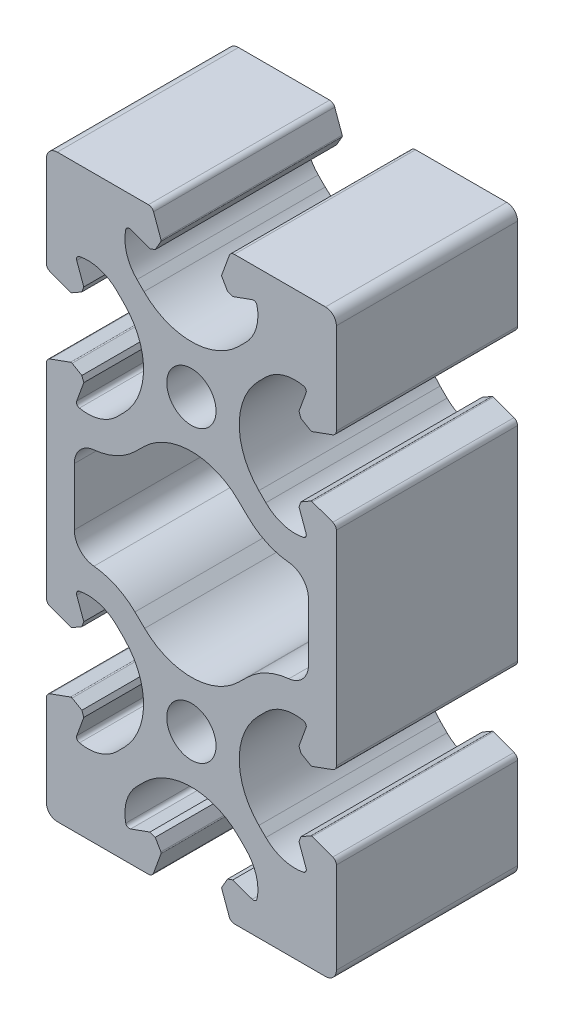
from build123d import *

# Parameters (mm, degrees)
SK_MAIN_EXTRUSION_R  = 3.4
MAIN_EXTRUSION_DEPTH = 25


with BuildPart() as part:
    # Sk Main Extrusion → Main Extrusion (new body)
    with BuildSketch(Plane.XY):
        with BuildLine():
            Line((16.671180212, 24.190076845), (19.506515108, 25.222054351))
            ThreePointArc((19.506515108, 25.222054351), (19.864364033, 25.496641489), (20, 25.926823816))
            Line((20, 25.926823816), (20, 38.5))
            ThreePointArc((20, 38.5), (19.560660172, 39.560660172), (18.5, 40))
            Line((18.5, 40), (5.926823816, 40))
            ThreePointArc((5.926823816, 40), (5.496641489, 39.864364033), (5.222054351, 39.506515107))
            Line((5.222054351, 39.506515107), (4.190076845, 36.671180212))
            ThreePointArc((4.190076845, 36.671180212), (4.175951326, 36.563886241), (4.208493649, 36.460675177))
            Line((4.208493649, 36.460675177), (4.987558066, 35.111296024))
            Line((4.987558066, 35.111296024), (5.718509166, 34.845251581))
            Line((5.718509166, 34.845251581), (8.396186179, 35.81984631))
            ThreePointArc((8.396186179, 35.81984631), (8.811074612, 35.786489799), (9.056960151, 35.450654467))
            ThreePointArc((9.056960151, 35.450654467), (8.933433013, 32.665882372), (7.504160339, 30.272684887))
            Line((7.504160339, 30.272684887), (6.540737726, 29.309262274))
            ThreePointArc((6.540737726, 29.309262274), (0, 26.6), (-6.540737726, 29.309262274))
            Line((-6.540737726, 29.309262274), (-7.504160339, 30.272684887))
            ThreePointArc((-7.504160339, 30.272684887), (-8.933433013, 32.665882372), (-9.056960151, 35.450654467))
            ThreePointArc((-9.056960151, 35.450654467), (-8.811074612, 35.786489799), (-8.396186179, 35.81984631))
            Line((-8.396186179, 35.81984631), (-5.718509166, 34.845251581))
            Line((-5.718509166, 34.845251581), (-4.987558066, 35.111296024))
            Line((-4.987558066, 35.111296024), (-4.208493649, 36.460675177))
            ThreePointArc((-4.208493649, 36.460675177), (-4.175951325, 36.563886241), (-4.190076845, 36.671180212))
            Line((-4.190076845, 36.671180212), (-5.222054351, 39.506515107))
            ThreePointArc((-5.222054351, 39.506515107), (-5.496641489, 39.864364033), (-5.926823816, 40))
            Line((-5.926823816, 40), (-18.5, 40))
            ThreePointArc((-18.5, 40), (-19.560660172, 39.560660172), (-20, 38.5))
            Line((-20, 38.5), (-20, 25.926823816))
            ThreePointArc((-20, 25.926823816), (-19.864364033, 25.496641489), (-19.506515107, 25.222054351))
            Line((-19.506515107, 25.222054351), (-16.671180212, 24.190076845))
            ThreePointArc((-16.671180212, 24.190076845), (-16.563886241, 24.175951326), (-16.460675176, 24.208493649))
            Line((-16.460675176, 24.208493649), (-15.111296024, 24.987558066))
            Line((-15.111296024, 24.987558066), (-14.845251581, 25.718509166))
            Line((-14.845251581, 25.718509166), (-15.81984631, 28.396186179))
            ThreePointArc((-15.81984631, 28.396186179), (-15.786489799, 28.811074612), (-15.450654467, 29.056960151))
            ThreePointArc((-15.450654467, 29.056960151), (-12.665882372, 28.933433013), (-10.272684887, 27.504160339))
            Line((-10.272684887, 27.504160339), (-9.309262274, 26.540737726))
            ThreePointArc((-9.309262274, 26.540737726), (-6.6, 20), (-9.309262274, 13.459262274))
            Line((-9.309262274, 13.459262274), (-10.272684887, 12.495839661))
            ThreePointArc((-10.272684887, 12.495839661), (-12.665882372, 11.066566987), (-15.450654467, 10.943039849))
            ThreePointArc((-15.450654467, 10.943039849), (-15.786489799, 11.188925388), (-15.81984631, 11.603813821))
            Line((-15.81984631, 11.603813821), (-14.845251581, 14.281490834))
            Line((-14.845251581, 14.281490834), (-15.111296024, 15.012441934))
            Line((-15.111296024, 15.012441934), (-16.460675176, 15.791506351))
            ThreePointArc((-16.460675176, 15.791506351), (-16.563886241, 15.824048675), (-16.671180212, 15.809923155))
            Line((-16.671180212, 15.809923155), (-19.506515107, 14.777945649))
            ThreePointArc((-19.506515107, 14.777945649), (-19.864364033, 14.503358511), (-20, 14.073176184))
            Line((-20, 14.073176184), (-20, -14.073176184))
            ThreePointArc((-20, -14.073176184), (-19.864364033, -14.503358511), (-19.506515107, -14.777945649))
            Line((-19.506515107, -14.777945649), (-16.671180212, -15.809923155))
            ThreePointArc((-16.671180212, -15.809923155), (-16.563886241, -15.824048675), (-16.460675176, -15.791506351))
            Line((-16.460675176, -15.791506351), (-15.111296024, -15.012441934))
            Line((-15.111296024, -15.012441934), (-14.845251581, -14.281490834))
            Line((-14.845251581, -14.281490834), (-15.81984631, -11.603813821))
            ThreePointArc((-15.81984631, -11.603813821), (-15.786489799, -11.188925388), (-15.450654467, -10.943039849))
            ThreePointArc((-15.450654467, -10.943039849), (-12.665882372, -11.066566987), (-10.272684887, -12.495839661))
            Line((-10.272684887, -12.495839661), (-9.309262274, -13.459262274))
            ThreePointArc((-9.309262274, -13.459262274), (-6.6, -20), (-9.309262274, -26.540737726))
            Line((-9.309262274, -26.540737726), (-10.272684887, -27.504160339))
            ThreePointArc((-10.272684887, -27.504160339), (-12.665882372, -28.933433013), (-15.450654467, -29.056960151))
            ThreePointArc((-15.450654467, -29.056960151), (-15.786489799, -28.811074612), (-15.81984631, -28.396186179))
            Line((-15.81984631, -28.396186179), (-14.845251581, -25.718509166))
            Line((-14.845251581, -25.718509166), (-15.111296024, -24.987558066))
            Line((-15.111296024, -24.987558066), (-16.460675176, -24.208493649))
            ThreePointArc((-16.460675176, -24.208493649), (-16.563886241, -24.175951326), (-16.671180212, -24.190076845))
            Line((-16.671180212, -24.190076845), (-19.506515107, -25.222054351))
            ThreePointArc((-19.506515107, -25.222054351), (-19.864364033, -25.496641489), (-20, -25.926823816))
            Line((-20, -25.926823816), (-20, -38.5))
            ThreePointArc((-20, -38.5), (-19.560660172, -39.560660172), (-18.5, -40))
            Line((-18.5, -40), (-5.926823816, -40))
            ThreePointArc((-5.926823816, -40), (-5.496641489, -39.864364033), (-5.222054351, -39.506515107))
            Line((-5.222054351, -39.506515107), (-4.190076845, -36.671180212))
            ThreePointArc((-4.190076845, -36.671180212), (-4.175951325, -36.563886241), (-4.208493649, -36.460675177))
            Line((-4.208493649, -36.460675177), (-4.987558066, -35.111296024))
            Line((-4.987558066, -35.111296024), (-5.718509166, -34.845251581))
            Line((-5.718509166, -34.845251581), (-8.396186179, -35.81984631))
            ThreePointArc((-8.396186179, -35.81984631), (-8.811074612, -35.786489799), (-9.056960151, -35.450654467))
            ThreePointArc((-9.056960151, -35.450654467), (-8.933433013, -32.665882372), (-7.504160339, -30.272684887))
            Line((-7.504160339, -30.272684887), (-6.540737726, -29.309262274))
            ThreePointArc((-6.540737726, -29.309262274), (0, -26.6), (6.540737726, -29.309262274))
            Line((6.540737726, -29.309262274), (7.504160339, -30.272684887))
            ThreePointArc((7.504160339, -30.272684887), (8.933433013, -32.665882372), (9.056960151, -35.450654467))
            ThreePointArc((9.056960151, -35.450654467), (8.811074612, -35.786489799), (8.396186179, -35.81984631))
            Line((8.396186179, -35.81984631), (5.718509166, -34.845251581))
            Line((5.718509166, -34.845251581), (4.987558066, -35.111296024))
            Line((4.987558066, -35.111296024), (4.208493649, -36.460675177))
            ThreePointArc((4.208493649, -36.460675177), (4.175951326, -36.563886241), (4.190076845, -36.671180212))
            Line((4.190076845, -36.671180212), (5.222054351, -39.506515107))
            ThreePointArc((5.222054351, -39.506515107), (5.496641489, -39.864364033), (5.926823816, -40))
            Line((5.926823816, -40), (18.5, -40))
            ThreePointArc((18.5, -40), (19.560660172, -39.560660172), (20, -38.5))
            Line((20, -38.5), (20, -25.926823816))
            ThreePointArc((20, -25.926823816), (19.864364033, -25.496641489), (19.506515108, -25.222054351))
            Line((19.506515108, -25.222054351), (16.671180212, -24.190076845))
            ThreePointArc((16.671180212, -24.190076845), (16.563886241, -24.175951325), (16.460675177, -24.208493649))
            Line((16.460675177, -24.208493649), (15.111296024, -24.987558066))
            Line((15.111296024, -24.987558066), (14.845251581, -25.718509166))
            Line((14.845251581, -25.718509166), (15.81984631, -28.396186179))
            ThreePointArc((15.81984631, -28.396186179), (15.786489799, -28.811074612), (15.450654467, -29.056960151))
            ThreePointArc((15.450654467, -29.056960151), (12.665882372, -28.933433013), (10.272684887, -27.504160339))
            Line((10.272684887, -27.504160339), (9.309262274, -26.540737726))
            ThreePointArc((9.309262274, -26.540737726), (6.6, -20), (9.309262274, -13.459262274))
            Line((9.309262274, -13.459262274), (10.272684887, -12.495839661))
            ThreePointArc((10.272684887, -12.495839661), (12.665882372, -11.066566987), (15.450654467, -10.943039849))
            ThreePointArc((15.450654467, -10.943039849), (15.786489799, -11.188925388), (15.81984631, -11.603813821))
            Line((15.81984631, -11.603813821), (14.845251581, -14.281490834))
            Line((14.845251581, -14.281490834), (15.111296024, -15.012441934))
            Line((15.111296024, -15.012441934), (16.460675177, -15.791506351))
            ThreePointArc((16.460675177, -15.791506351), (16.563886241, -15.824048675), (16.671180212, -15.809923155))
            Line((16.671180212, -15.809923155), (19.506515108, -14.777945649))
            ThreePointArc((19.506515108, -14.777945649), (19.864364033, -14.503358511), (20, -14.073176184))
            Line((20, -14.073176184), (20, 14.073176184))
            ThreePointArc((20, 14.073176184), (19.864364033, 14.503358511), (19.506515108, 14.777945649))
            Line((19.506515108, 14.777945649), (16.671180212, 15.809923155))
            ThreePointArc((16.671180212, 15.809923155), (16.563886241, 15.824048675), (16.460675177, 15.791506351))
            Line((16.460675177, 15.791506351), (15.111296024, 15.012441934))
            Line((15.111296024, 15.012441934), (14.845251581, 14.281490834))
            Line((14.845251581, 14.281490834), (15.81984631, 11.603813821))
            ThreePointArc((15.81984631, 11.603813821), (15.786489799, 11.188925388), (15.450654467, 10.943039849))
            ThreePointArc((15.450654467, 10.943039849), (12.665882372, 11.066566987), (10.272684887, 12.495839661))
            Line((10.272684887, 12.495839661), (9.309262274, 13.459262274))
            ThreePointArc((9.309262274, 13.459262274), (6.6, 20), (9.309262274, 26.540737726))
            Line((9.309262274, 26.540737726), (10.272684887, 27.504160339))
            ThreePointArc((10.272684887, 27.504160339), (12.665882372, 28.933433013), (15.450654467, 29.056960151))
            ThreePointArc((15.450654467, 29.056960151), (15.786489799, 28.811074612), (15.81984631, 28.396186179))
            Line((15.81984631, 28.396186179), (14.845251581, 25.718509166))
            Line((14.845251581, 25.718509166), (15.111296024, 24.987558066))
            Line((15.111296024, 24.987558066), (16.460675177, 24.208493649))
            ThreePointArc((16.460675177, 24.208493649), (16.563886241, 24.175951325), (16.671180212, 24.190076845))
        make_face()
        with Locations((0, -20)):
            Circle(SK_MAIN_EXTRUSION_R, mode=Mode.SUBTRACT)
        with Locations((0, 20)):
            Circle(SK_MAIN_EXTRUSION_R, mode=Mode.SUBTRACT)
        with BuildLine():
            Line((-6.45015637, 10.880081659), (-7.785929627, 9.580558241))
            ThreePointArc((-7.785929627, 9.580558241), (-10.392188513, 7.784550764), (-13.445312973, 6.949889591))
            ThreePointArc((-13.445312973, 6.949889591), (-15.373278988, 5.978667107), (-16.15, 3.964459932))
            Line((-16.15, 3.964459932), (-16.15, -3.964459932))
            ThreePointArc((-16.15, -3.964459932), (-15.373278988, -5.978667107), (-13.445312973, -6.949889591))
            ThreePointArc((-13.445312973, -6.949889591), (-10.392188513, -7.784550764), (-7.785929627, -9.580558241))
            Line((-7.785929627, -9.580558241), (-6.45015637, -10.880081659))
            ThreePointArc((-6.45015637, -10.880081659), (0, -13.5), (6.45015637, -10.880081659))
            Line((6.45015637, -10.880081659), (7.785929627, -9.580558241))
            ThreePointArc((7.785929627, -9.580558241), (10.392188513, -7.784550764), (13.445312973, -6.949889591))
            ThreePointArc((13.445312973, -6.949889591), (15.373278988, -5.978667107), (16.15, -3.964459932))
            Line((16.15, -3.964459932), (16.15, 3.964459932))
            ThreePointArc((16.15, 3.964459932), (15.373278988, 5.978667107), (13.445312973, 6.949889591))
            ThreePointArc((13.445312973, 6.949889591), (10.392188513, 7.784550764), (7.785929627, 9.580558241))
            Line((7.785929627, 9.580558241), (6.45015637, 10.880081659))
            ThreePointArc((6.45015637, 10.880081659), (0, 13.5), (-6.45015637, 10.880081659))
        make_face(mode=Mode.SUBTRACT)
    extrude(amount=-MAIN_EXTRUSION_DEPTH)


solid = part.part
